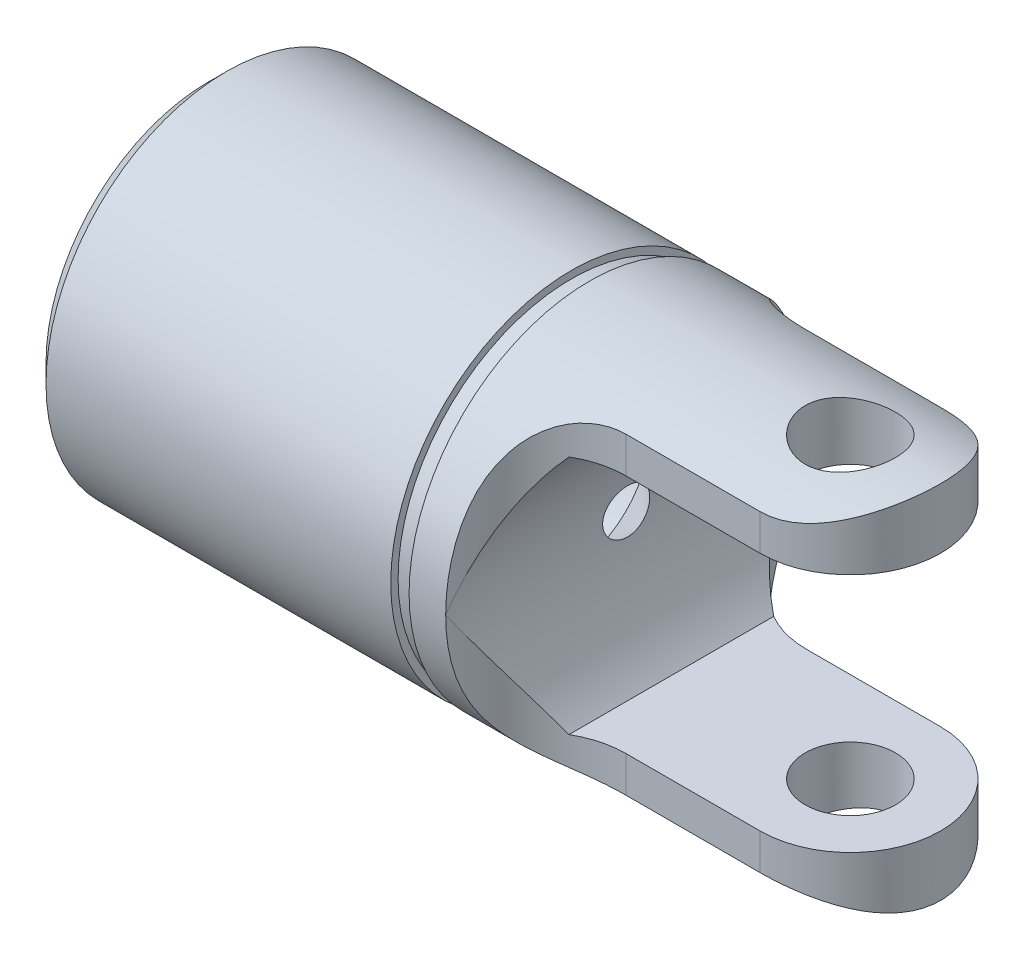
from build123d import *

# Parameters (mm, degrees)
CHAMFER1_SIZE       = 0.714375
EXTRUDE1_DEPTH      = 28.33544088
EXTRUDE1_DEPTH_BACK = 28.33544088
EXTRUDE3_DEPTH      = 28.335440933
EXTRUDE3_DEPTH_BACK = 28.335440933
SKETCH4_R           = 3.175
EXTRUDE4_DEPTH      = 14.2875
EXTRUDE6_DEPTH      = 28.335440933
EXTRUDE6_DEPTH_BACK = 28.335440933
SKETCH6_R           = 1.7859375


with BuildPart() as part:
    # Sketch1 → Revolve1 (revolve)
    with BuildSketch(Plane(origin=(0, 0, 0), x_dir=(1, 0, 0), z_dir=(0, 1, 0)), mode=Mode.PRIVATE) as revolve1_sk:
        Polygon((-25.4, 7.14375), (-11.043046875, 7.14375), (-11.043046875, 6.85403125), (-10.31875, 6.85403125), (-10.31875, 7.14375), (3.571875, 7.14375), (3.571875, 0), (-25.4, 0), align=None)
    revolve(revolve1_sk.sketch.rotate(Axis((-25.4, 0, 0), (1, 0, 0)), 180), axis=Axis((-25.4, 0, 0), (1, 0, 0)))

    # Chamfer1
    chamfer1_edges = [part.edges().sort_by_distance(p)[0] for p in [
        (-25.4, 0, -7.14375),
    ]]
    chamfer(chamfer1_edges, length=CHAMFER1_SIZE)

    # Sketch2 → Extrude1 (cut, two sides: drawn at the far end of the back side and taken through both)
    with BuildSketch(Plane(origin=(0, 0, 0), x_dir=(1, 0, 0), z_dir=(0, 1, 0)).offset(-EXTRUDE1_DEPTH_BACK)):
        with BuildLine():
            Line((-8.87015625, 7.14375), (7.14375, 7.14375))
            Line((7.14375, 7.14375), (7.14375, -7.14375))
            Line((7.14375, -7.14375), (-8.87015625, -7.14375))
            ThreePointArc((-8.87015625, -7.14375), (-7.823978284, -4.618052966), (-5.29828125, -3.571875))
            Line((-5.29828125, -3.571875), (0, -3.571875))
            ThreePointArc((0, -3.571875), (3.571875, 0), (0, 3.571875))
            Line((0, 3.571875), (-5.29828125, 3.571875))
            ThreePointArc((-5.29828125, 3.571875), (-7.823978284, 4.618052966), (-8.87015625, 7.14375))
        make_face()
    extrude(amount=EXTRUDE1_DEPTH + EXTRUDE1_DEPTH_BACK, mode=Mode.SUBTRACT)

    # Sketch3 → Extrude3 (cut, two sides: drawn at the far end of the back side and taken through both)
    with BuildSketch(Plane.XY.offset(-EXTRUDE3_DEPTH_BACK)):
        with BuildLine():
            Line((-7.08421875, 4.7577375), (7.14375, 4.7577375))
            Line((7.14375, 4.7577375), (7.14375, -4.7577375))
            Line((7.14375, -4.7577375), (-7.08421875, -4.7577375))
            ThreePointArc((-7.08421875, -4.7577375), (-8.87015625, 0), (-7.08421875, 4.7577375))
        make_face()
    extrude(amount=EXTRUDE3_DEPTH + EXTRUDE3_DEPTH_BACK, mode=Mode.SUBTRACT)

    # Sketch4 → Extrude4 (cut)
    with BuildSketch(Plane.ZY.offset(25.4)):
        Circle(SKETCH4_R)
    extrude(amount=-EXTRUDE4_DEPTH, mode=Mode.SUBTRACT)

    # Extrude5 cone 1 section (through the dimple's axis) → Extrude5 (revolve, cut)
    with BuildSketch(Plane(origin=(-11.1125, 0, 0), x_dir=(0, 0, 1), z_dir=(0, 1, 0))):
        Polygon((0, 0), (3.175, 0), (0, 3.175), align=None)
    revolve(axis=Axis((-11.1125, 0, 0), (1, 0, 0)), mode=Mode.SUBTRACT)

    # Sketch6 → Extrude6 (cut, two sides: drawn at the far end of the back side and taken through both)
    with BuildSketch(Plane(origin=(0, 0, 0), x_dir=(1, 0, 0), z_dir=(0, 1, 0)).offset(-EXTRUDE6_DEPTH_BACK)):
        with Locations(Location((0, 0, 0), (0, 0, 270))):
            Circle(SKETCH6_R)
    extrude(amount=EXTRUDE6_DEPTH + EXTRUDE6_DEPTH_BACK, mode=Mode.SUBTRACT)


solid = part.part
